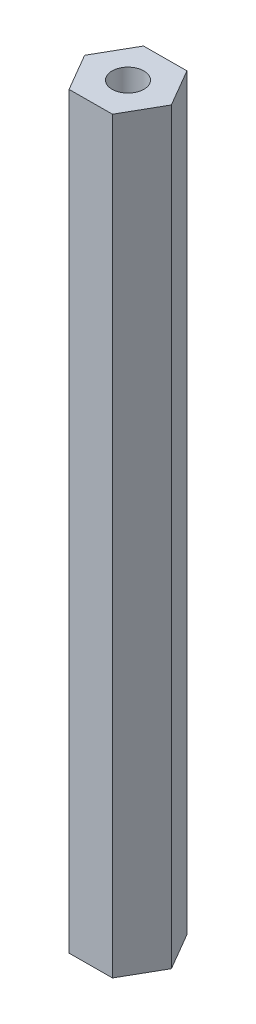
from build123d import *

# Parameters (mm, degrees)
BOSS_EXTRUDE1_DEPTH = 63.5
SKETCH2_R           = 1.35255
CUT_EXTRUDE1_DEPTH  = 64.5


with BuildPart() as part:
    # Sketch1 → Boss-Extrude1 (new body)
    with BuildSketch(Plane(origin=(0, 0, 0), x_dir=(1, 0, 0), z_dir=(0, 1, 0))):
        Polygon((-1.847278959, 3.166763929), (-3.66613749, -0.016408542), (-1.818858531, -3.183172471), (1.847278959, -3.166763929), (3.66613749, 0.016408542), (1.818858531, 3.183172471), align=None)
    extrude(amount=BOSS_EXTRUDE1_DEPTH)

    # Sketch2 → Cut-Extrude1 (cut, through all)
    with BuildSketch(Plane(origin=(0, 63.5, 0), x_dir=(1, 0, 0), z_dir=(0, 1, 0))):
        Circle(SKETCH2_R)
    extrude(amount=-CUT_EXTRUDE1_DEPTH, mode=Mode.SUBTRACT)


solid = part.part
